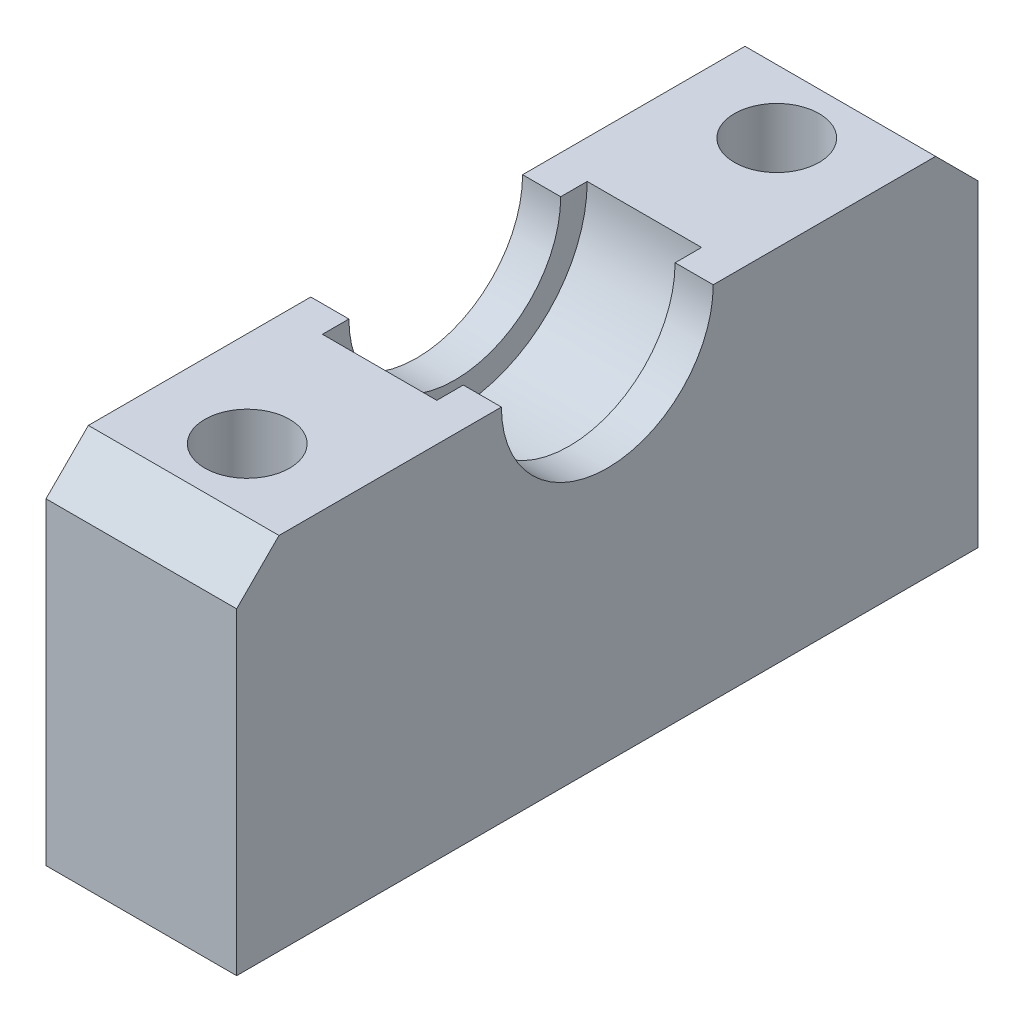
from build123d import *

# Parameters (mm, degrees)
BOSS_EXTRUDE1_DEPTH      = 4.5
BOSS_EXTRUDE1_DEPTH_BACK = 4.5
CUT_EXTRUDE1_DEPTH       = 2.7
CUT_EXTRUDE1_DEPTH_BACK  = 2.7
SKETCH2_R                = 6.25
SKETCH3_R                = 2
CUT_EXTRUDE3_DEPTH       = 25.80927246
CHAMFER1_SIZE            = 2


with BuildPart() as part:
    # Sketch1 → Boss-Extrude1 (new, two sides: drawn at the far end of the back side and taken through both)
    with BuildSketch(Plane(origin=(0, 0, 0), x_dir=(0, 0, -1), z_dir=(1, 0, 0)).offset(-BOSS_EXTRUDE1_DEPTH_BACK)):
        with BuildLine():
            Line((5, 8.5), (17.5, 8.5))
            Line((17.5, 8.5), (17.5, -8.5))
            Line((17.5, -8.5), (-17.5, -8.5))
            Line((-17.5, -8.5), (-17.5, 8.5))
            Line((-17.5, 8.5), (-5, 8.5))
            ThreePointArc((-5, 8.5), (0, 3.5), (5, 8.5))
        make_face()
    extrude(amount=BOSS_EXTRUDE1_DEPTH + BOSS_EXTRUDE1_DEPTH_BACK)

    # Sketch2 → Cut-Extrude1 (cut, two sides: drawn at the far end of the back side and taken through both)
    with BuildSketch(Plane(origin=(0, 0, 0), x_dir=(0, 0, -1), z_dir=(1, 0, 0)).offset(-CUT_EXTRUDE1_DEPTH_BACK)):
        with Locations((0, 8.5)):
            Circle(SKETCH2_R)
    extrude(amount=CUT_EXTRUDE1_DEPTH + CUT_EXTRUDE1_DEPTH_BACK, mode=Mode.SUBTRACT)

    # Sketch3 → Cut-Extrude3 (cut, through all)
    with BuildSketch(Plane(origin=(0, 8.5, 0), x_dir=(1, 0, 0), z_dir=(0, 1, 0))):
        with Locations((0, 12.5)):
            Circle(SKETCH3_R)
        with Locations((0, -12.5)):
            Circle(SKETCH3_R)
    extrude(amount=-CUT_EXTRUDE3_DEPTH, mode=Mode.SUBTRACT)

    # Chamfer1
    chamfer1_edges = [part.edges().sort_by_distance(p)[0] for p in [
        (0, 8.5, -17.5),
        (0, 8.5, 17.5),
    ]]
    chamfer(chamfer1_edges, length=CHAMFER1_SIZE)


solid = part.part
